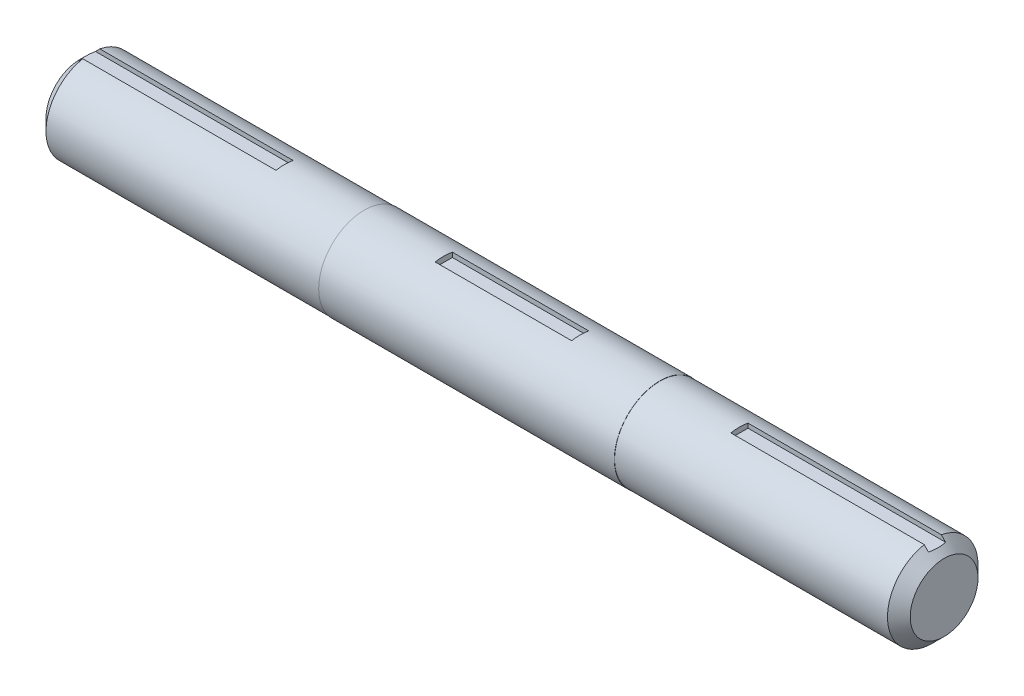
from build123d import *

# Parameters (mm, degrees)
SKETCH1_R           = 12.6365
BOSS_EXTRUDE1_DEPTH = 79.375
SKETCH2_R           = 12.7
BOSS_EXTRUDE2_DEPTH = 82.55
SKETCH3_R           = 12.6365
BOSS_EXTRUDE3_DEPTH = 79.375
CHAMFER1_SIZE       = 3.175
CUT_EXTRUDE1_DEPTH  = 57.15
CUT_EXTRUDE2_START  = -241.3
CUT_EXTRUDE2_DEPTH  = 57.15
CUT_EXTRUDE3_START  = -120.65
CUT_EXTRUDE3_DEPTH  = 19.05


with BuildPart() as part:
    # Sketch1 → Boss-Extrude1 (new body)
    with BuildSketch(Plane(origin=(0, 0, 0), x_dir=(0, 0, -1), z_dir=(1, 0, 0))):
        Circle(SKETCH1_R)
    extrude(amount=-BOSS_EXTRUDE1_DEPTH)

    # Sketch2 → Boss-Extrude2 (add)
    with BuildSketch(Plane.ZY.offset(79.375)):
        Circle(SKETCH2_R)
    extrude(amount=BOSS_EXTRUDE2_DEPTH)

    # Sketch3 → Boss-Extrude3 (add)
    with BuildSketch(Plane.ZY.offset(161.925)):
        Circle(SKETCH3_R)
    extrude(amount=BOSS_EXTRUDE3_DEPTH)

    # Chamfer1
    chamfer1_edges = [part.edges().sort_by_distance(p)[0] for p in [
        (-241.3, 0, -12.6365),
        (0, 0, 12.6365),
    ]]
    chamfer(chamfer1_edges, length=CHAMFER1_SIZE)

    # Sketch4 → Cut-Extrude1 (cut)
    with BuildSketch(Plane(origin=(0, 0, 0), x_dir=(0, 0, -1), z_dir=(1, 0, 0))):
        with BuildLine():
            Line((-2.3876, 11.176), (2.3876, 11.176))
            Line((2.3876, 11.176), (2.3876, 12.473546658))
            ThreePointArc((2.3876, 12.473546658), (0, 12.7), (-2.3876, 12.473546658))
            Line((-2.3876, 12.473546658), (-2.3876, 11.176))
        make_face()
    extrude(amount=-CUT_EXTRUDE1_DEPTH, mode=Mode.SUBTRACT)

    # Sketch4_2 → Cut-Extrude2 (cut)
    with BuildSketch(Plane(origin=(0, 0, 0), x_dir=(0, 0, -1), z_dir=(1, 0, 0)).offset(CUT_EXTRUDE2_START)):
        with BuildLine():
            Line((-2.3876, 11.176), (2.3876, 11.176))
            Line((2.3876, 11.176), (2.3876, 12.473546658))
            ThreePointArc((2.3876, 12.473546658), (0, 12.7), (-2.3876, 12.473546658))
            Line((-2.3876, 12.473546658), (-2.3876, 11.176))
        make_face()
    extrude(amount=CUT_EXTRUDE2_DEPTH, mode=Mode.SUBTRACT)

    # Sketch4_4 → Cut-Extrude3 (cut, symmetric)
    with BuildSketch(Plane(origin=(0, 0, 0), x_dir=(0, 0, -1), z_dir=(1, 0, 0)).offset(CUT_EXTRUDE3_START)):
        with BuildLine():
            Line((-2.3876, 11.176), (2.3876, 11.176))
            Line((2.3876, 11.176), (2.3876, 12.473546658))
            ThreePointArc((2.3876, 12.473546658), (0, 12.7), (-2.3876, 12.473546658))
            Line((-2.3876, 12.473546658), (-2.3876, 11.176))
        make_face()
    extrude(amount=CUT_EXTRUDE3_DEPTH, both=True, mode=Mode.SUBTRACT)


solid = part.part
